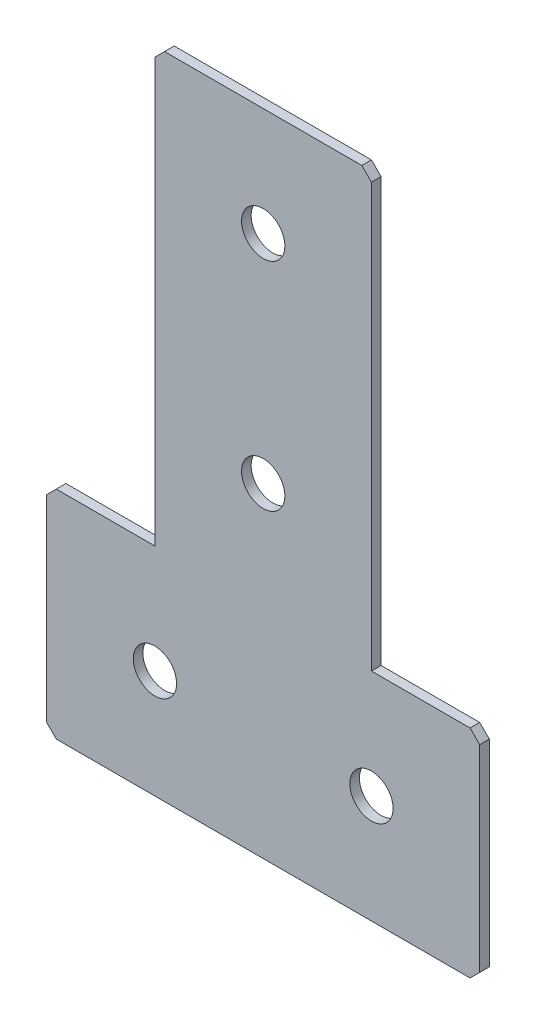
from build123d import *

# Parameters (mm, degrees)
EXTRUDE_1_DEPTH   = 2
HOLE_WIZARD_M81_D = 9
CHAMFER_1_SIZE    = 2


with BuildPart() as part:
    # Эскиз1 → Бобышка-Вытянуть1 (new body)
    with BuildSketch(Plane(origin=(0, 0, 0), x_dir=(1, 0, 0), z_dir=(0, 0, -1))):
        Polygon((-45, 135), (45, 135), (45, 90), (22.5, 90), (22.5, 0), (-22.5, 0), (-22.5, 90), (-45, 90), align=None)
    extrude(amount=EXTRUDE_1_DEPTH)

    # Отверстие с зазором M81 (through all)
    with Locations(Plane(origin=(0, 0, -2), x_dir=(1, 0, 0), z_dir=(0, 0, -1))):
        with Locations((0, 22.5), (-22.5, 112.5), (22.5, 112.5), (0, 67.5)):
            Hole(HOLE_WIZARD_M81_D / 2)

    # Фаска1
    chamfer_1_edges = [part.edges().sort_by_distance(p)[0] for p in [
        (-45, -90, -1),
        (-45, -135, -1),
        (45, -135, -1),
        (45, -90, -1),
        (22.5, 0, -1),
        (-22.5, 0, -1),
    ]]
    chamfer(chamfer_1_edges, length=CHAMFER_1_SIZE)


solid = part.part
